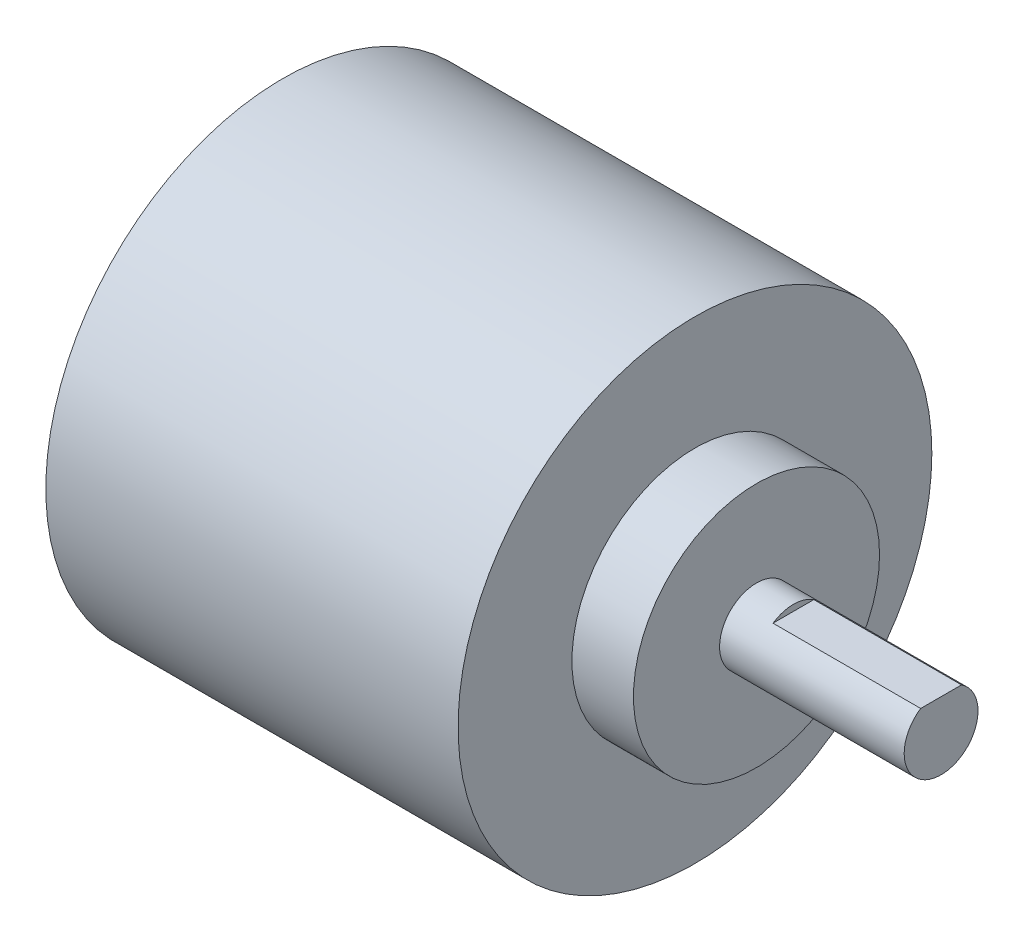
from build123d import *

# Parameters (mm, degrees)
ESQUISSE_BASE_CODEUR_R    = 19.25
BASE_CODEUR_DEPTH         = 33.5
ESQUISSE_PLATEAU_CODEUR_R = 10
PLATEAU_CODEUR_DEPTH      = 5
ESQUISSE_ARBRE_R          = 3
ARBRE_DEPTH               = 15
USINAGE_ARBRE_DEPTH       = 12


with BuildPart() as part:
    # esquisse_base_codeur → base_codeur (new body)
    with BuildSketch(Plane(origin=(0, 0, 0), x_dir=(0, 0, -1), z_dir=(1, 0, 0))):
        Circle(ESQUISSE_BASE_CODEUR_R)
    extrude(amount=BASE_CODEUR_DEPTH)

    # esquisse_plateau_codeur → plateau_codeur (add)
    with BuildSketch(Plane(origin=(33.5, 0, 0), x_dir=(0, 0, -1), z_dir=(1, 0, 0))):
        Circle(ESQUISSE_PLATEAU_CODEUR_R)
    extrude(amount=PLATEAU_CODEUR_DEPTH)

    # esquisse_arbre → arbre (add)
    with BuildSketch(Plane(origin=(38.5, 0, 0), x_dir=(0, 0, -1), z_dir=(1, 0, 0))):
        Circle(ESQUISSE_ARBRE_R)
    extrude(amount=ARBRE_DEPTH)

    # esquisse_usinage_arbre → usinage_arbre (cut)
    with BuildSketch(Plane(origin=(53.5, 0, 0), x_dir=(0, 0, -1), z_dir=(1, 0, 0))):
        with BuildLine():
            Line((-1.658312395, 2.5), (1.658312395, 2.5))
            ThreePointArc((1.658312395, 2.5), (0, 3), (-1.658312395, 2.5))
        make_face()
    extrude(amount=-USINAGE_ARBRE_DEPTH, mode=Mode.SUBTRACT)


solid = part.part
